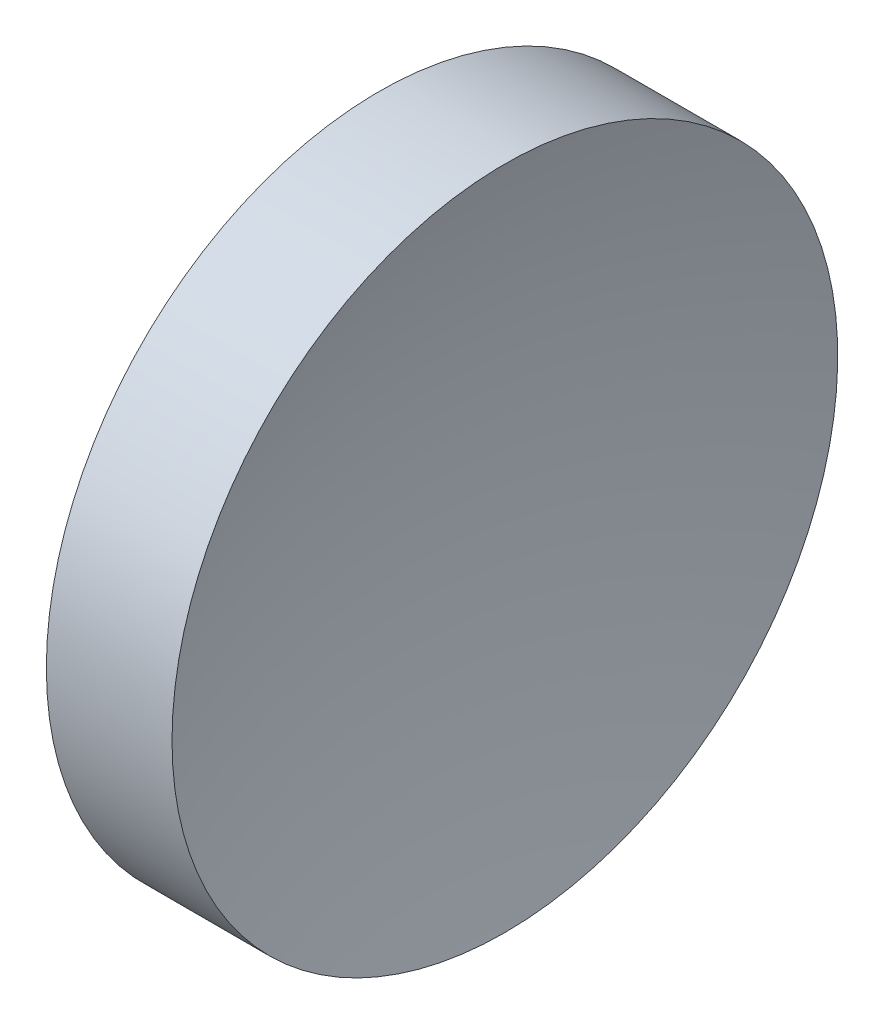
from build123d import *


with BuildPart() as part:
    # 草图1 → 旋转1 (revolve)
    with BuildSketch(Plane.XY, mode=Mode.PRIVATE) as revolve_1_sk:
        with BuildLine():
            Line((47.753708501, 28.477595635), (47.753708501, 34.827595635))
            Line((47.753708501, 34.827595635), (50.150904411, 34.827595635))
            ThreePointArc((50.150904411, 34.827595635), (49.479115866, 31.684130388), (49.253708501, 28.477595635))
            Line((49.253708501, 28.477595635), (47.753708501, 28.477595635))
        make_face()
    revolve(revolve_1_sk.sketch.rotate(Axis((44.782091903, 28.477595635, 0), (1, 0, 0)), 180), axis=Axis((44.782091903, 28.477595635, 0), (1, 0, 0)))  # turned: the seam where the file's is


solid = part.part
